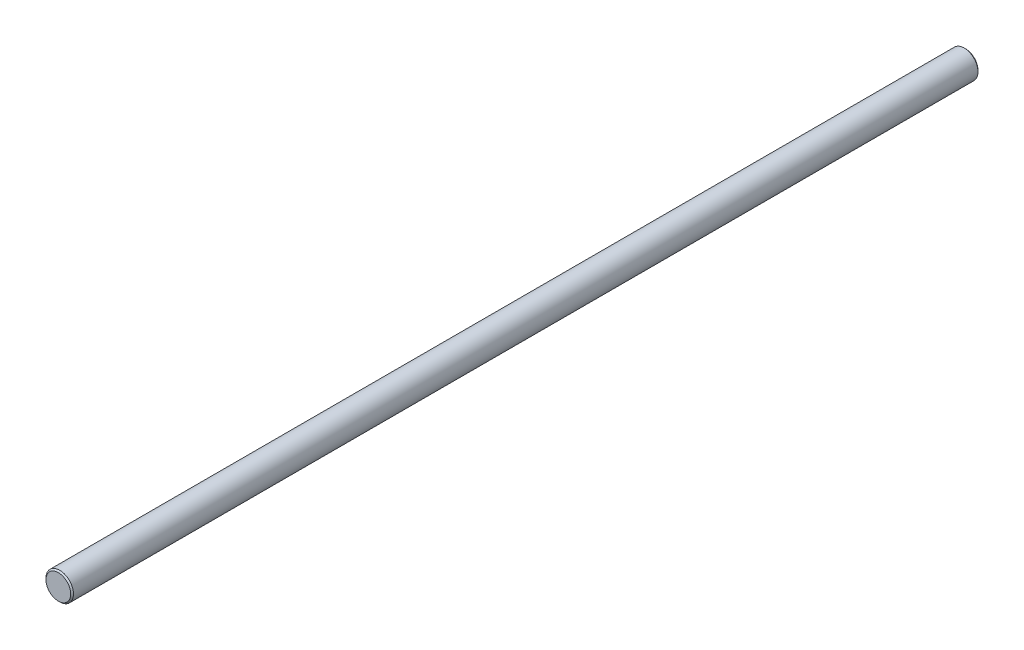
from build123d import *

# Parameters (mm, degrees)
SKETCH1_R           = 5
BOSS_EXTRUDE1_DEPTH = 330
CHAMFER1_SIZE       = 0.5


with BuildPart() as part:
    # Sketch1 → Boss-Extrude1 (new body)
    with BuildSketch(Plane.XY):
        Circle(SKETCH1_R)
    extrude(amount=-BOSS_EXTRUDE1_DEPTH)

    # Chamfer1
    chamfer1_edges = [part.edges().sort_by_distance(p)[0] for p in [
        (-5, 0, 0),
        (-5, 0, -330),
    ]]
    chamfer(chamfer1_edges, length=CHAMFER1_SIZE)


solid = part.part
